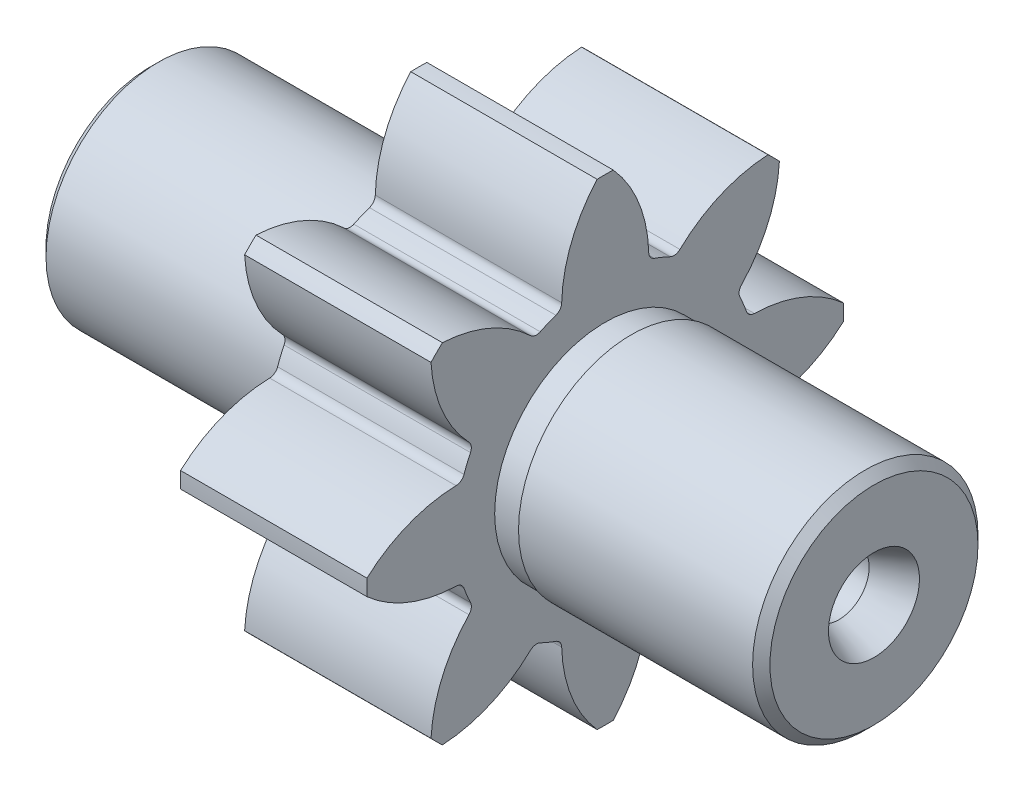
from build123d import *

# Parameters (mm, degrees)
SKETCH_1_R                       = 13
EXTRUDE_1_DEPTH                  = 31
SKETCH_2_R                       = 17.25
EXTRUDE_2_DEPTH                  = 21.5
SKETCH_3_R                       = 13
EXTRUDE_3_DEPTH                  = 31
HOLE_WIZARD_7_0_7_1_D            = 7
SKETCH_10_W                      = 3
SKETCH_10_H                      = 3
EXTRUDE_4_DEPTH                  = 21.5
FILLET_1_R                       = 1
PATTERN_CIRCULAR_1_COUNT         = 8
FILLET_1_OF_PATTERN_CIRCULAR_1_R = 1
CHAMFER_1_SIZE                   = 1


with BuildPart() as part:
    # Эскиз1 → Бобышка-Вытянуть1 (new body)
    with BuildSketch(Plane(origin=(0, 0, 0), x_dir=(0, 0, -1), z_dir=(1, 0, 0))):
        Circle(SKETCH_1_R)
    extrude(amount=EXTRUDE_1_DEPTH)

    # Эскиз2 → Бобышка-Вытянуть2 (add)
    with BuildSketch(Plane(origin=(31, 0, 0), x_dir=(0, 0, -1), z_dir=(1, 0, 0))):
        Circle(SKETCH_2_R)
    extrude(amount=EXTRUDE_2_DEPTH)

    # Эскиз3 → Бобышка-Вытянуть3 (add)
    with BuildSketch(Plane(origin=(52.5, 0, 0), x_dir=(0, 0, -1), z_dir=(1, 0, 0))):
        Circle(SKETCH_3_R)
    extrude(amount=EXTRUDE_3_DEPTH)

    # Эскиз4 → Отверстие1 (revolve, cut)
    with BuildSketch(Plane(origin=(83.5, 0, 0), x_dir=(0, 0, -1), z_dir=(0, 1, 0))):
        Polygon((0, 0), (0, 11.30043031), (0.5, 11), (5.25, 0), align=None)
    revolve(axis=Axis((93.401672523, 0, 0), (-1, 0, 0)), mode=Mode.SUBTRACT)

    # Эскиз6 → Отверстие2 (revolve, cut)
    with BuildSketch(Plane.ZX):
        Polygon((0, 0), (0, 11.30043031), (0.5, 11), (5.25, 0), align=None)
    revolve(axis=Axis((-9.901672523, 0, 0), (1, 0, 0)), mode=Mode.SUBTRACT)

    # Диаметр отверстия Ø7.0 (7)1 (through all)
    with Locations(Plane.ZY):
        with Locations((0, 0)):
            Hole(HOLE_WIZARD_7_0_7_1_D / 2)

    # Эскиз10 → Вырез-Повернуть1 (revolve, cut)
    with BuildSketch(Plane.XY):
        with Locations((29.5, 14.25)):
            Rectangle(SKETCH_10_W, SKETCH_10_H)
        with Locations((54, 14.25)):
            Rectangle(SKETCH_10_W, SKETCH_10_H)
    revolve(axis=Axis((0, 0, 0), (1, 0, 0)), mode=Mode.SUBTRACT)

    # Эскиз11 → Бобышка-Вытянуть4 (add)
    with BuildSketch(Plane.ZY.offset(-31)):
        with BuildLine():
            ThreePointArc((5.012313719, 16.18214113), (0, 16.94063105), (-5.012313719, 16.18214113))
            ThreePointArc((-5.012313719, 16.18214113), (-4.071446885, 22.231312684), (-0.927672188, 27.484348715))
            ThreePointArc((-0.927672188, 27.484348715), (0, 27.5), (0.927672188, 27.484348715))
            ThreePointArc((0.927672188, 27.484348715), (4.071446885, 22.231312684), (5.012313719, 16.18214113))
        make_face()
    extrude_4 = extrude(amount=-EXTRUDE_4_DEPTH)

    # Скругление1
    fillet_1_edges = [part.edges().sort_by_distance(p)[0] for p in [
        (41.75, 16.502985059, -5.021352821),
        (41.75, 16.502985059, 5.021352821),
    ]]
    fillet(fillet_1_edges, radius=FILLET_1_R)

    # Круговой массив1: Бобышка-Вытянуть4 ×8 about axis
    pattern_circular_1_axis = Axis((0, 0, 0), (1, 0, 0))
    for i in range(1, PATTERN_CIRCULAR_1_COUNT):
        add(extrude_4.rotate(pattern_circular_1_axis, i * 360 / PATTERN_CIRCULAR_1_COUNT))

    # Скругление1 of Круговой массив1
    fillet_1_of_pattern_circular_1_edges = [part.edges().sort_by_distance(p)[0] for p in [
        (41.75, 15.220005275, 8.118740015),
        (41.75, 8.118740015, 15.220005275),
        (41.75, 5.021352821, 16.502985059),
        (41.75, -5.021352821, 16.502985059),
        (41.75, -8.118740015, 15.220005275),
        (41.75, -15.220005275, 8.118740015),
        (41.75, -16.502985059, 5.021352821),
        (41.75, -16.502985059, -5.021352821),
        (41.75, -15.220005275, -8.118740015),
        (41.75, -8.118740015, -15.220005275),
        (41.75, -5.021352821, -16.502985059),
        (41.75, 5.021352821, -16.502985059),
        (41.75, 8.118740015, -15.220005275),
        (41.75, 15.220005275, -8.118740015),
    ]]
    fillet(fillet_1_of_pattern_circular_1_edges, radius=FILLET_1_OF_PATTERN_CIRCULAR_1_R)

    # Фаска1
    chamfer_1_edges = [part.edges().sort_by_distance(p)[0] for p in [
        (83.5, 0, 13),
        (0, 0, 13),
    ]]
    chamfer(chamfer_1_edges, length=CHAMFER_1_SIZE)


solid = part.part
